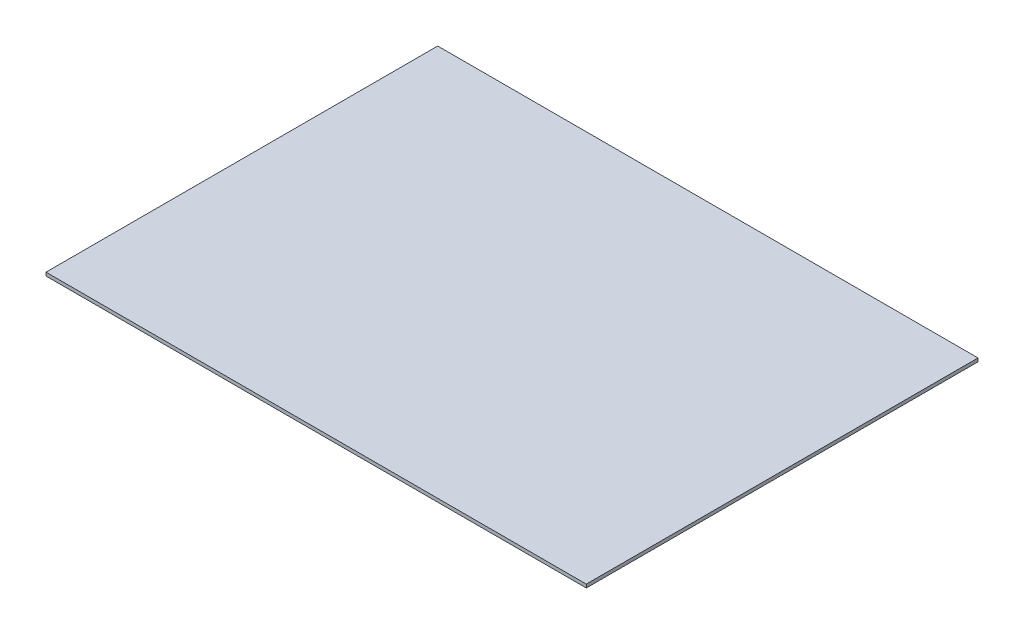
from build123d import *

# Parameters (mm, degrees)
SKETCH1_W      = 20
SKETCH1_H      = 14.5
EXTRUDE1_DEPTH = 0.125


with BuildPart() as part:
    # Sketch1 → Extrude1 (new body)
    with BuildSketch(Plane(origin=(0, 0, 0), x_dir=(1, 0, 0), z_dir=(0, 1, 0))):
        Rectangle(SKETCH1_W, SKETCH1_H)
    extrude(amount=EXTRUDE1_DEPTH)


solid = part.part
